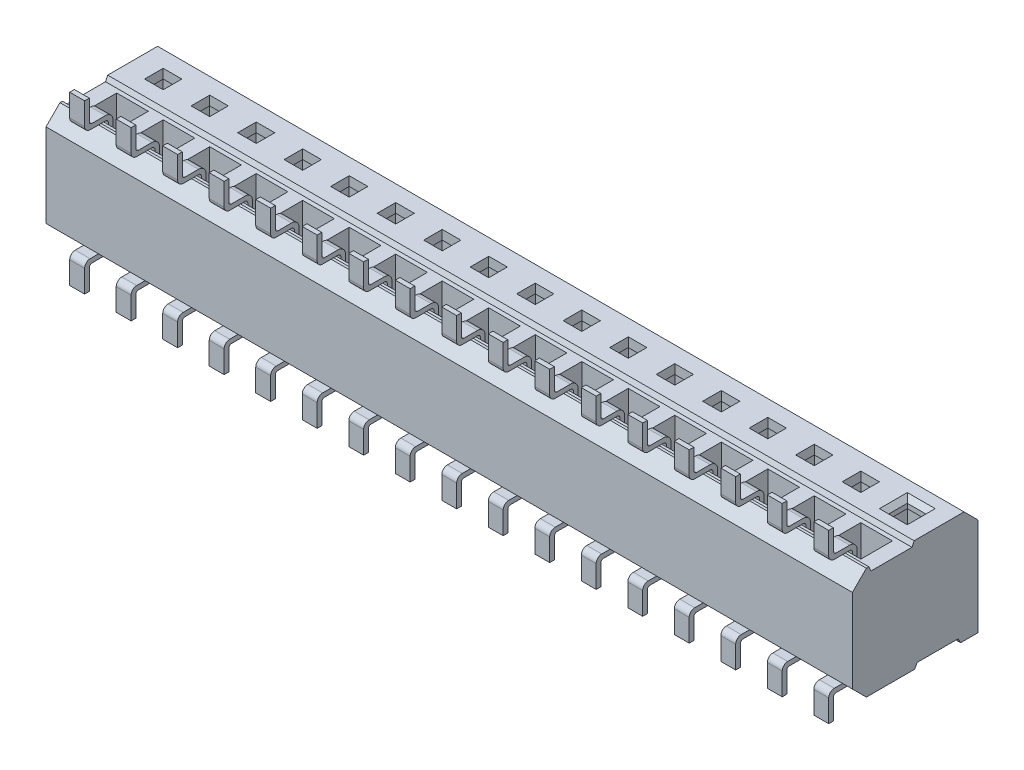
from build123d import *

# Parameters (mm, degrees)
SKETCH1_W             = 22.0218
SKETCH1_H             = 3.429
MAIN_BODY_DEPTH       = 3.048
SKETCH2_W             = 0.508
SKETCH2_H             = 0.508
CUT_EXTRUDE1_DEPTH    = 2.794
CHAMFER1_SIZE         = 0.127
SKETCH30_W            = 0.8636
SKETCH30_H            = 2.794
PIN_CUT_DH_DEPTH      = 0.4318
BODY_CUT_DH_DEPTH     = 23.0218
DH_CUT_PATTERN_COUNT  = 17
DH_CUT_PATTERN_PITCH  = 1.27
LEAD_PIN_DH_DEPTH     = 0.2032
LEAD_PATTERN_DH_COUNT = 17
LEAD_PATTERN_DH_PITCH = 1.27


with BuildPart() as part:
    # Sketch1 → Main Body (new body)
    with BuildSketch(Plane(origin=(0, 0, 0), x_dir=(1, 0, 0), z_dir=(0, 1, 0))):
        Rectangle(SKETCH1_W, SKETCH1_H)
    extrude(amount=MAIN_BODY_DEPTH)

    # Sketch2 → Cut-Extrude1 (cut)
    with BuildSketch(Plane(origin=(0, 3.048, 0), x_dir=(-1, 0, 0), z_dir=(0, 1, 0))):
        with Locations((-10.16, -0.635)):
            Rectangle(SKETCH2_W, SKETCH2_H)
        with Locations((-10.16, 0.635)):
            Rectangle(SKETCH2_W, SKETCH2_H)
    cut_extrude1 = extrude(amount=-CUT_EXTRUDE1_DEPTH, mode=Mode.SUBTRACT)

    # Chamfer1
    chamfer1_edges = [part.edges().sort_by_distance(p)[0] for p in [
        (10.414, 3.048, -0.635),
        (10.16, 3.048, -0.889),
        (9.906, 3.048, -0.635),
        (10.16, 3.048, -0.381),
        (10.16, 3.048, 0.381),
        (9.906, 3.048, 0.635),
        (10.16, 3.048, 0.889),
        (10.414, 3.048, 0.635),
    ]]
    chamfer(chamfer1_edges, length=CHAMFER1_SIZE)

    # Sketch30 → Pin Cut-DH (cut, symmetric)
    with BuildSketch(Plane(origin=(10.16, 0, 0), x_dir=(0, 0, -1), z_dir=(1, 0, 0))):
        with Locations((-0.635, 1.651)):
            Rectangle(SKETCH30_W, SKETCH30_H)
        with Locations((0.635, 1.397)):
            Rectangle(SKETCH30_W, SKETCH30_H)
    pin_cut_dh = extrude(amount=PIN_CUT_DH_DEPTH, both=True, mode=Mode.SUBTRACT)

    # Sketch10 → Body Cut-DH (cut, through all)
    with BuildSketch(Plane(origin=(11.0109, 0, 0), x_dir=(0, 0, -1), z_dir=(1, 0, 0))):
        Polygon((-1.7145, 3.048), (-1.3335, 3.048), (-1.7145, 2.667), align=None)
        Polygon((-1.26492, 3.048), (-0.03048, 3.048), (-0.0889, 2.921), (-1.2065, 2.921), align=None)
        Polygon((1.7145, 2.667), (1.3335, 3.048), (1.7145, 3.048), align=None)
        Polygon((-1.7145, 0.381), (-1.3335, 0), (-1.7145, 0), align=None)
        Polygon((-0.01524, 0), (0.05334, 0.127), (1.17094, 0.127), (1.23952, 0), align=None)
    extrude(amount=-BODY_CUT_DH_DEPTH, mode=Mode.SUBTRACT)

    # DH Cut Pattern: Cut-Extrude1, Pin Cut-DH ×17
    with Locations(*[(-i * DH_CUT_PATTERN_PITCH, 0, 0) for i in range(1, DH_CUT_PATTERN_COUNT)]):
        add(cut_extrude1, mode=Mode.SUBTRACT)
        add(pin_cut_dh, mode=Mode.SUBTRACT)

    # Sketch11 → Lead Pin-DH (add, symmetric)
    with BuildSketch(Plane(origin=(10.16, 0, 0), x_dir=(0, 0, -1), z_dir=(1, 0, 0))):
        with BuildLine():
            Line((-1.5621, 3.048), (-1.143, 3.048))
            ThreePointArc((-1.143, 3.048), (-1.089118463, 3.025681537), (-1.0668, 2.9718))
            Line((-1.0668, 2.9718), (-1.0668, 2.48666))
            Line((-1.0668, 2.48666), (-0.9398, 2.48666))
            Line((-0.9398, 2.48666), (-0.9398, 2.9718))
            ThreePointArc((-0.9398, 2.9718), (-0.999315902, 3.115484098), (-1.143, 3.175))
            Line((-1.143, 3.175), (-1.5113, 3.175))
            ThreePointArc((-1.5113, 3.175), (-1.565181537, 3.197318463), (-1.5875, 3.2512))
            Line((-1.5875, 3.2512), (-1.5875, 3.81))
            Line((-1.5875, 3.81), (-1.7145, 3.81))
            Line((-1.7145, 3.81), (-1.7145, 3.2004))
            ThreePointArc((-1.7145, 3.2004), (-1.669863073, 3.092636927), (-1.5621, 3.048))
        make_face()
        with BuildLine():
            Line((0.2032, 0.686543888), (0.2032, 0.0762))
            ThreePointArc((0.2032, 0.0762), (0.180881537, 0.022318463), (0.127, 0))
            Line((0.127, 0), (-1.5621, 0))
            ThreePointArc((-1.5621, 0), (-1.669863073, -0.044636927), (-1.7145, -0.1524))
            Line((-1.7145, -0.1524), (-1.7145, -0.762))
            Line((-1.7145, -0.762), (-1.5875, -0.762))
            Line((-1.5875, -0.762), (-1.5875, -0.2032))
            ThreePointArc((-1.5875, -0.2032), (-1.565181537, -0.149318463), (-1.5113, -0.127))
            Line((-1.5113, -0.127), (0.127, -0.127))
            ThreePointArc((0.127, -0.127), (0.270684098, -0.067484098), (0.3302, 0.0762))
            Line((0.3302, 0.0762), (0.3302, 0.686543888))
            Line((0.3302, 0.686543888), (0.2032, 0.686543888))
        make_face()
    lead_pin_dh = extrude(amount=LEAD_PIN_DH_DEPTH, both=True)

    # Lead Pattern-DH: Lead Pin-DH ×17
    with Locations(*[(-i * LEAD_PATTERN_DH_PITCH, 0, 0) for i in range(1, LEAD_PATTERN_DH_COUNT)]):
        add(lead_pin_dh)


solid = part.part
